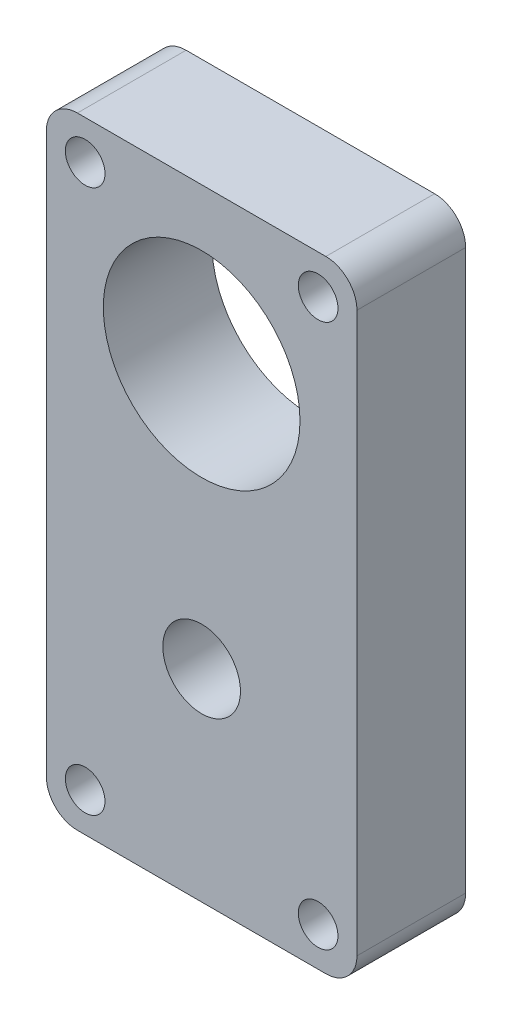
from build123d import *

# Parameters (mm, degrees)
SKETCH1_R           = 12.665
SKETCH1_R_2         = 2.554599
SKETCH1_R_3         = 5
BOSS_EXTRUDE1_DEPTH = 14
FILLET1_R           = 4
SKETCH11_R          = 7.5
BOSS_EXTRUDE3_DEPTH = 2


with BuildPart() as part:
    # Sketch1 → Boss-Extrude1 (new body)
    with BuildSketch(Plane.XY):
        Polygon((20, -10), (20, 20), (-20, 20), (-20, -10), (-20, -60), (20, -60), align=None)
        Circle(SKETCH1_R, mode=Mode.SUBTRACT)
        with Locations((-15, 15)):
            Circle(SKETCH1_R_2, mode=Mode.SUBTRACT)
        with Locations((15, 15)):
            Circle(SKETCH1_R_2, mode=Mode.SUBTRACT)
        with Locations((-15, -55)):
            Circle(SKETCH1_R_2, mode=Mode.SUBTRACT)
        with Locations((15, -55)):
            Circle(SKETCH1_R_2, mode=Mode.SUBTRACT)
        with Locations((0, -34)):
            Circle(SKETCH1_R_3, mode=Mode.SUBTRACT)
    extrude(amount=BOSS_EXTRUDE1_DEPTH)

    # Fillet1
    fillet1_edges = [part.edges().sort_by_distance(p)[0] for p in [
        (-20, 20, 7),
        (20, 20, 7),
        (20, -60, 7),
        (-20, -60, 7),
    ]]
    fillet(fillet1_edges, radius=FILLET1_R)

    # Sketch11 → Boss-Extrude3 (add)
    with BuildSketch(Plane(origin=(0, 0, 0), x_dir=(-1, 0, 0), z_dir=(0, 0, -1))):
        with Locations((0, -34)):
            Circle(SKETCH11_R)
    extrude(amount=-BOSS_EXTRUDE3_DEPTH)


solid = part.part
